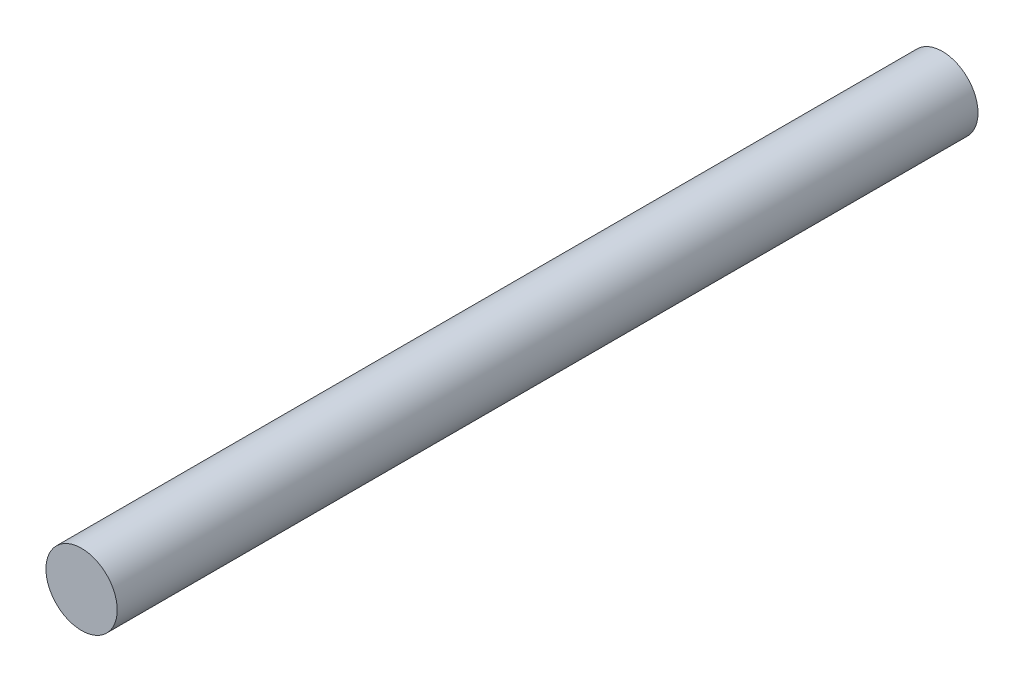
from build123d import *

# Parameters (mm, degrees)
SKETCH1_R           = 2.6289
BOSS_EXTRUDE1_DEPTH = 63.5


with BuildPart() as part:
    # Sketch1 → Boss-Extrude1 (new body)
    with BuildSketch(Plane.XY):
        Circle(SKETCH1_R)
    extrude(amount=BOSS_EXTRUDE1_DEPTH)


solid = part.part
